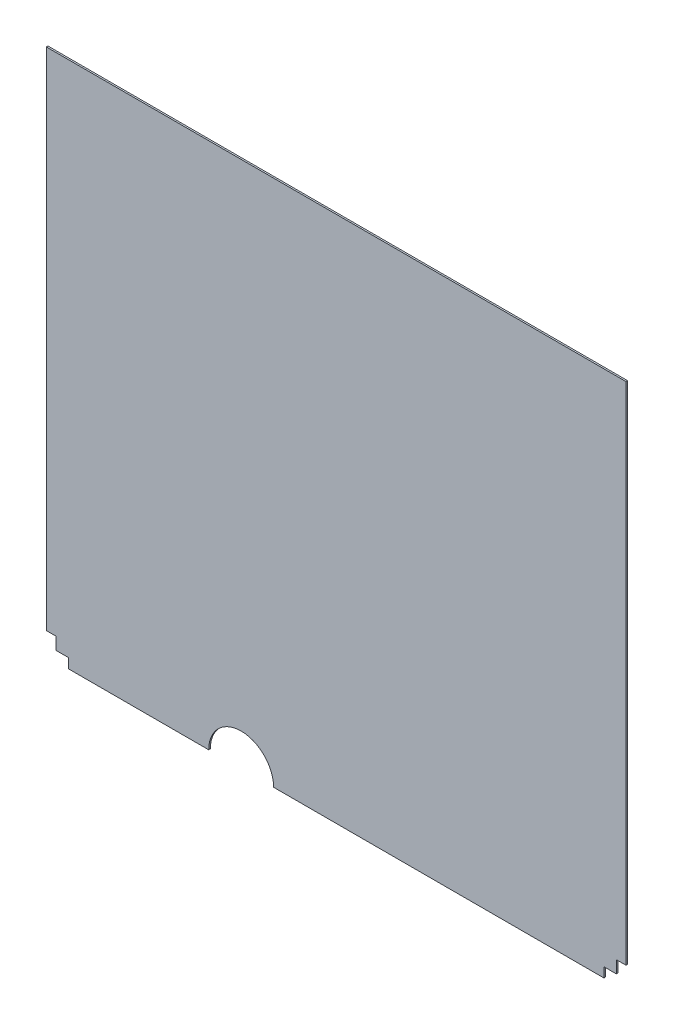
from build123d import *

# Parameters (mm, degrees)
BOSS_EXTRUDE1_DEPTH = 2.54


with BuildPart() as part:
    # Sketch1 → Boss-Extrude1 (new body)
    with BuildSketch(Plane.XY):
        with BuildLine():
            Line((0, 825.5), (0, 34.544))
            Line((0, 34.544), (15.24, 34.544))
            Line((15.24, 34.544), (15.24, 15.24))
            Line((15.24, 15.24), (34.544, 15.24))
            Line((34.544, 15.24), (34.544, 0))
            Line((34.544, 0), (254, 0))
            ThreePointArc((254, 0), (304.8, 50.8), (355.6, 0))
            Line((355.6, 0), (872.45698, 0))
            Line((872.45698, 0), (872.45698, 15.24))
            Line((872.45698, 15.24), (891.76098, 15.24))
            Line((891.76098, 15.24), (891.76098, 34.544))
            Line((891.76098, 34.544), (907.00098, 34.544))
            Line((907.00098, 34.544), (907.00098, 825.5))
            Line((907.00098, 825.5), (0, 825.5))
        make_face()
    extrude(amount=BOSS_EXTRUDE1_DEPTH)


solid = part.part
